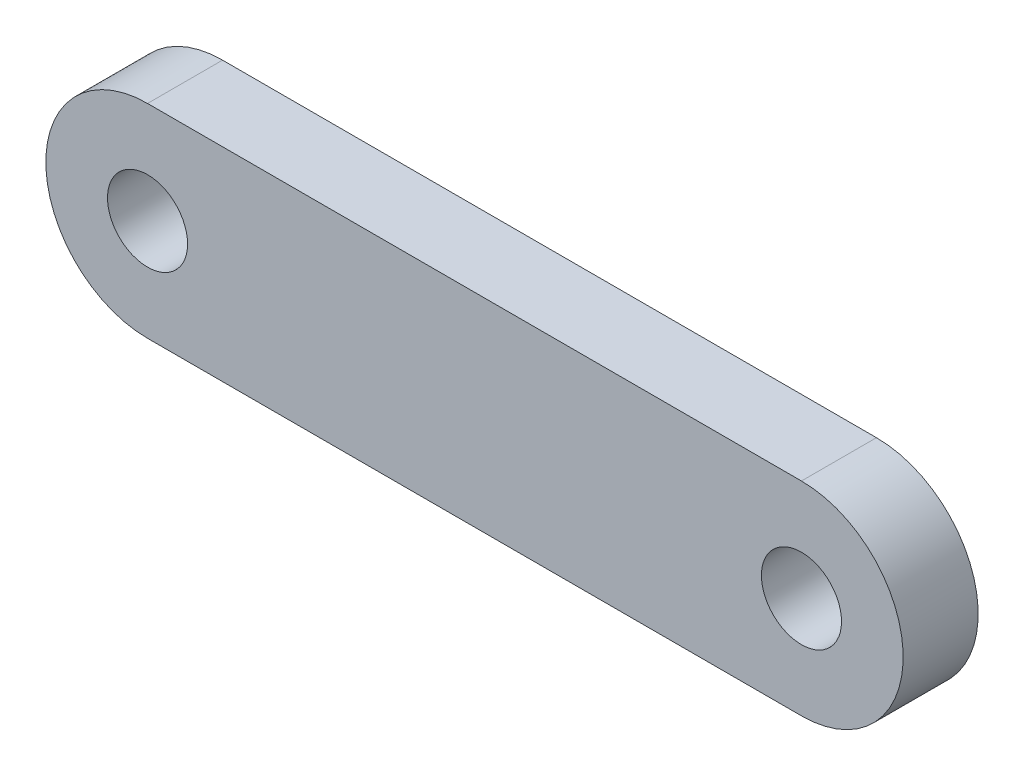
from build123d import *

# Parameters (mm, degrees)
SKETCH1_R           = 3.15
BOSS_EXTRUDE1_DEPTH = 5.9


with BuildPart() as part:
    # Sketch1 → Boss-Extrude1 (new body)
    with BuildSketch(Plane.XY):
        with BuildLine():
            Line((25.7175, -8), (-25.7175, -8))
            ThreePointArc((-25.7175, -8), (-33.7175, 0), (-25.7175, 8))
            Line((-25.7175, 8), (25.7175, 8))
            ThreePointArc((25.7175, 8), (33.7175, 0), (25.7175, -8))
        make_face()
        with Locations((25.7175, 0)):
            Circle(SKETCH1_R, mode=Mode.SUBTRACT)
        with Locations((-25.7175, 0)):
            Circle(SKETCH1_R, mode=Mode.SUBTRACT)
    extrude(amount=BOSS_EXTRUDE1_DEPTH)


solid = part.part
